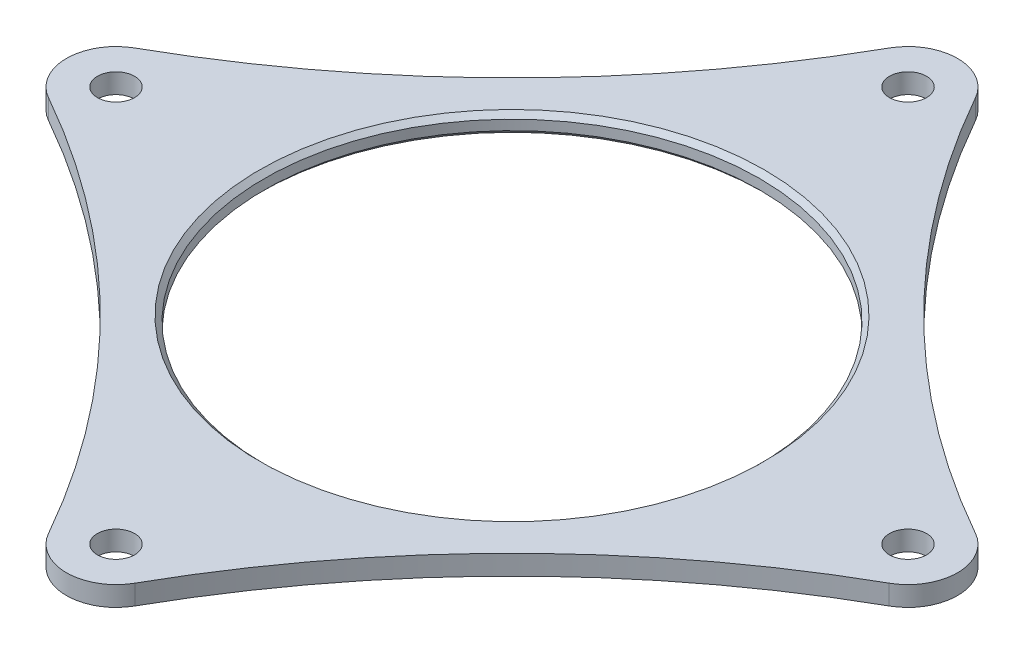
from build123d import *

# Parameters (mm, degrees)
SKETCH1_W                        = 228.6
SKETCH1_H                        = 228.6
BOSS_EXTRUDE1_DEPTH              = 5.08
SKETCH2_R                        = 63.5
CUT_EXTRUDE1_DEPTH               = 6.08
CUT_EXTRUDE2_DEPTH               = 6.08
CIRPATTERN1_COUNT                = 4
F_3_8_0_375_DIAMETER_HOLE1_D     = 9.525
F_3_8_0_375_DIAMETER_HOLE1_DEPTH = 5.081
CIRPATTERN2_COUNT                = 4
CHAMFER1_SIZE                    = 1.27


with BuildPart() as part:
    # Sketch1 → Boss-Extrude1 (new body)
    with BuildSketch(Plane(origin=(0, 0, 0), x_dir=(1, 0, 0), z_dir=(0, 1, 0))):
        Rectangle(SKETCH1_W, SKETCH1_H)
    extrude(amount=BOSS_EXTRUDE1_DEPTH)

    # Sketch2 → Cut-Extrude1 (cut, through all)
    with BuildSketch(Plane(origin=(0, 5.08, 0), x_dir=(1, 0, 0), z_dir=(0, 1, 0))):
        Circle(SKETCH2_R)
    extrude(amount=-CUT_EXTRUDE1_DEPTH, mode=Mode.SUBTRACT)

    # Sketch3 → Cut-Extrude2 (cut, through all)
    with BuildSketch(Plane(origin=(0, 5.08, 0), x_dir=(1, 0, 0), z_dir=(0, 1, 0))):
        with BuildLine():
            Line((114.3, 114.3), (0, 114.3))
            ThreePointArc((0, 114.3), (6.410086185, 112.56361232), (11.06735431, 107.829259072))
            ThreePointArc((11.06735431, 107.829259072), (52.809318084, 52.809318084), (107.829259072, 11.06735431))
            ThreePointArc((107.829259072, 11.06735431), (112.56361232, 6.410086185), (114.3, 0))
            Line((114.3, 0), (114.3, 114.3))
        make_face()
    cut_extrude2 = extrude(amount=-CUT_EXTRUDE2_DEPTH, mode=Mode.SUBTRACT)

    # CirPattern1: Cut-Extrude2 ×4 about axis
    cirpattern1_axis = Axis((0, 0, 0), (0, 1, 0))
    for i in range(1, CIRPATTERN1_COUNT):
        add(cut_extrude2.rotate(cirpattern1_axis, i * 360 / CIRPATTERN1_COUNT), mode=Mode.SUBTRACT)

    # 3/8 (0.375) Diameter Hole1
    with Locations(Plane(origin=(0, 5.08, 0), x_dir=(1, 0, 0), z_dir=(0, 1, 0))):
        with Locations((101.6, 0)):
            f_3_8_0_375_diameter_hole1 = Hole(F_3_8_0_375_DIAMETER_HOLE1_D / 2, depth=F_3_8_0_375_DIAMETER_HOLE1_DEPTH)

    # CirPattern2: 3/8 (0.375) Diameter Hole1 ×4 about axis
    cirpattern2_axis = Axis((0, 0, 0), (0, 1, 0))
    for i in range(1, CIRPATTERN2_COUNT):
        add(f_3_8_0_375_diameter_hole1.rotate(cirpattern2_axis, i * 360 / CIRPATTERN2_COUNT), mode=Mode.SUBTRACT)

    # Chamfer1
    chamfer1_edges = [part.edges().sort_by_distance(p)[0] for p in [
        (-63.5, 0, 0),
        (-63.5, 5.08, 0),
    ]]
    chamfer(chamfer1_edges, length=CHAMFER1_SIZE)


solid = part.part
